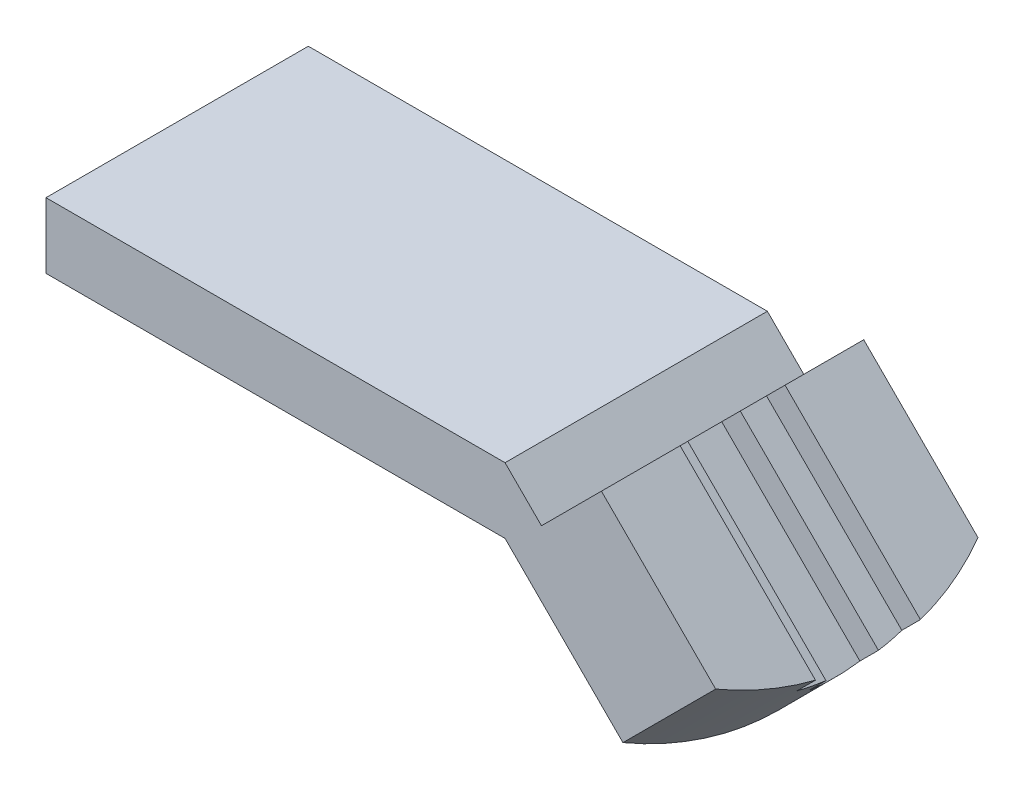
from build123d import *

# Parameters (mm, degrees)
BOSS_EXTRUDE1_DEPTH      = 20
CUT_EXTRUDE5_DEPTH       = 6
CUT_EXTRUDE5_DEPTH_BACK  = 45.944197614
CUT_EXTRUDE10_DEPTH      = 8.5
CUT_EXTRUDE10_DEPTH_BACK = 43.444197614


with BuildPart() as part:
    # Sketch2 → Boss-Extrude1 (new body)
    with BuildSketch(Plane.XY):
        Polygon((0, 0), (35, 0), (45.883024287, -10.883024287), (52.954092099, -3.811956475), (42.347490381, 6.794645243), (37.776422569, 2.223577431), (35, 5), (0, 5), align=None)
    extrude(amount=BOSS_EXTRUDE1_DEPTH)

    # Sketch3 → Cut-Extrude5 (cut, two sides)
    with BuildSketch(Plane(origin=(28.383024287, -28.383024287, 0), x_dir=(0, 0, -1), z_dir=(0.707106781, -0.707106781, 0))) as cut_extrude5_sk:
        Polygon((-14, 134.13575902), (-14, 34.748737342), (-14, 32.748737342), (-12, 32.748737342), (-12, 30.748737342), (-8, 30.748737342), (-8, 32.748737342), (-6, 32.748737342), (-6, 34.748737342), (-6, 134.13575902), (-6, 332.909802377), (-14, 332.909802377), align=None)
    extrude(amount=CUT_EXTRUDE5_DEPTH, mode=Mode.SUBTRACT)
    extrude(cut_extrude5_sk.sketch, amount=-CUT_EXTRUDE5_DEPTH_BACK, mode=Mode.SUBTRACT)

    # Sketch4 → Cut-Extrude10 (cut, two sides)
    with BuildSketch(Plane(origin=(24.571067812, 24.571067812, 0), x_dir=(0, 0, -1), z_dir=(0.707106781, 0.707106781, 0))) as cut_extrude10_sk:
        with BuildLine():
            Line((-109.647389073, 14.29777825), (-20, -37.460165963))
            ThreePointArc((-20, -37.460165963), (-10, -40.139657887), (0, -37.460165963))
            Line((0, -37.460165963), (89.647389073, 14.29777825))
            Line((89.647389073, 14.29777825), (89.647389073, -192.733998604))
            Line((89.647389073, -192.733998604), (-109.647389073, -192.733998604))
            Line((-109.647389073, -192.733998604), (-109.647389073, 14.29777825))
        make_face()
    extrude(amount=CUT_EXTRUDE10_DEPTH, mode=Mode.SUBTRACT)
    extrude(cut_extrude10_sk.sketch, amount=-CUT_EXTRUDE10_DEPTH_BACK, mode=Mode.SUBTRACT)


solid = part.part
